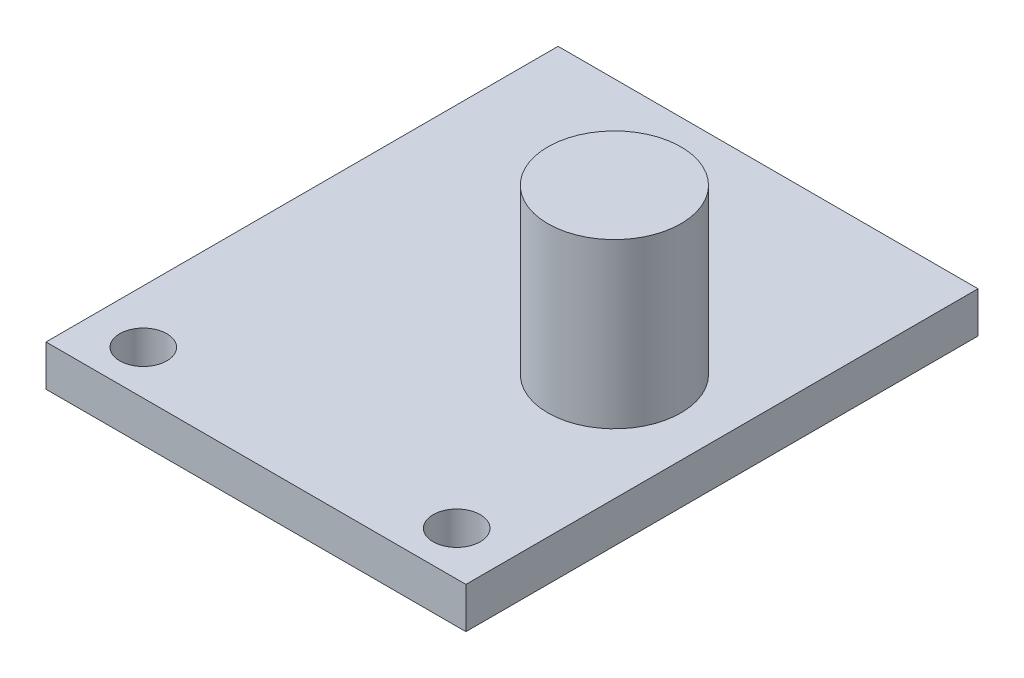
from build123d import *

# Parameters (mm, degrees)
SKETCH1_W           = 20.5
SKETCH1_H           = 25
BOSS_EXTRUDE1_DEPTH = 2
SKETCH2_R           = 1.15
CUT_EXTRUDE1_DEPTH  = 3
SKETCH3_R           = 3.25
BOSS_EXTRUDE2_DEPTH = 8


with BuildPart() as part:
    # Sketch1 → Boss-Extrude1 (new body)
    with BuildSketch(Plane(origin=(0, 0, 0), x_dir=(1, 0, 0), z_dir=(0, 1, 0))):
        Rectangle(SKETCH1_W, SKETCH1_H)
    extrude(amount=BOSS_EXTRUDE1_DEPTH)

    # Sketch2 → Cut-Extrude1 (cut, through all)
    with BuildSketch(Plane(origin=(0, 2, 0), x_dir=(1, 0, 0), z_dir=(0, 1, 0))):
        with Locations((7.65, -10.35)):
            Circle(SKETCH2_R)
        with Locations((-7.65, -10.35)):
            Circle(SKETCH2_R)
    extrude(amount=-CUT_EXTRUDE1_DEPTH, mode=Mode.SUBTRACT)

    # Sketch3 → Boss-Extrude2 (add)
    with BuildSketch(Plane(origin=(0, 2, 0), x_dir=(1, 0, 0), z_dir=(0, 1, 0))):
        with Locations((5, 0)):
            Circle(SKETCH3_R)
    extrude(amount=BOSS_EXTRUDE2_DEPTH)


solid = part.part
